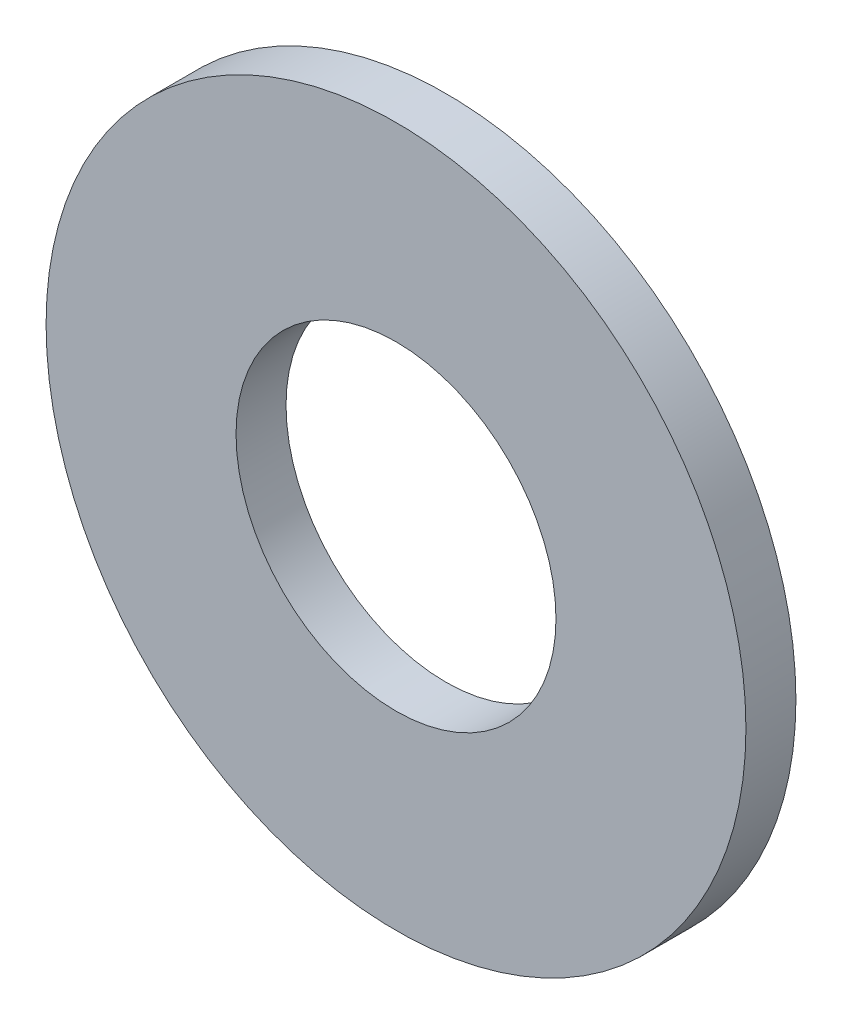
from build123d import *

# Parameters (mm, degrees)
SKETCH1_R           = 3.5
SKETCH1_R_2         = 1.6
BOSS_EXTRUDE1_DEPTH = 0.5


with BuildPart() as part:
    # Sketch1 → Boss-Extrude1 (new body)
    with BuildSketch(Plane.XY):
        Circle(SKETCH1_R)
        Circle(SKETCH1_R_2, mode=Mode.SUBTRACT)
    extrude(amount=BOSS_EXTRUDE1_DEPTH)


solid = part.part
